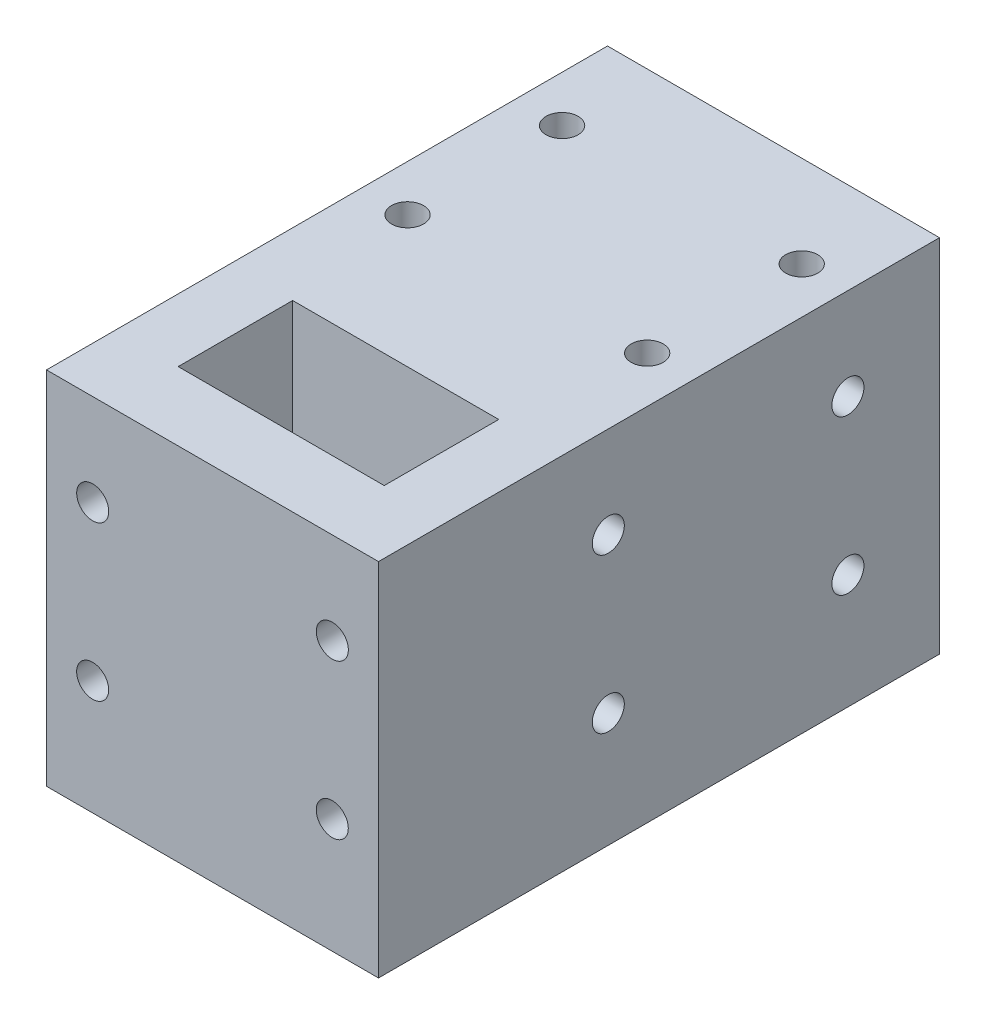
from build123d import *

# Parameters (mm, degrees)
SKETCH1_W           = 29
SKETCH1_H           = 49
BOSS_EXTRUDE1_DEPTH = 31.5
SKETCH2_W           = 18
SKETCH2_H           = 10
CUT_EXTRUDE1_DEPTH  = 32.5
SKETCH3_R           = 1.4
CUT_EXTRUDE2_DEPTH  = 3.4
SKETCH4_R           = 1.4
CUT_EXTRUDE3_DEPTH  = 3.4
SKETCH5_R           = 1.4
CUT_EXTRUDE4_DEPTH  = 3.4
CUT_EXTRUDE5_DEPTH  = 12


with BuildPart() as part:
    # Sketch1 → Boss-Extrude1 (new body)
    with BuildSketch(Plane(origin=(0, 0, 0), x_dir=(1, 0, 0), z_dir=(0, 1, 0))):
        with Locations((-2.710031348, 9.123824451)):
            Rectangle(SKETCH1_W, SKETCH1_H)
    extrude(amount=BOSS_EXTRUDE1_DEPTH)

    # Sketch2 → Cut-Extrude1 (cut, through all)
    with BuildSketch(Plane(origin=(0, 31.5, 0), x_dir=(1, 0, 0), z_dir=(0, 1, 0))):
        with Locations((-2.710031348, -4.376175549)):
            Rectangle(SKETCH2_W, SKETCH2_H)
    extrude(amount=-CUT_EXTRUDE1_DEPTH, mode=Mode.SUBTRACT)

    # Sketch3 → Cut-Extrude2 (cut)
    with BuildSketch(Plane(origin=(0, 31.5, 0), x_dir=(1, 0, 0), z_dir=(0, 1, 0))):
        with Locations((-13.175031348, 25.623824451)):
            Circle(SKETCH3_R)
        with Locations((-13.175031348, 12.123824451)):
            Circle(SKETCH3_R)
        with Locations((7.754968652, 25.623824451)):
            Circle(SKETCH3_R)
        with Locations((7.754968652, 12.123824451)):
            Circle(SKETCH3_R)
    extrude(amount=-CUT_EXTRUDE2_DEPTH, mode=Mode.SUBTRACT)

    # Sketch4 → Cut-Extrude3 (cut)
    with BuildSketch(Plane.ZY.offset(17.210031348)):
        with Locations((-25.623824451, 23.5)):
            Circle(SKETCH4_R)
        with Locations((-4.693824451, 23.5)):
            Circle(SKETCH4_R)
        with Locations((-25.623824451, 10)):
            Circle(SKETCH4_R)
        with Locations((-4.693824451, 10)):
            Circle(SKETCH4_R)
    cut_extrude3 = extrude(amount=-CUT_EXTRUDE3_DEPTH, mode=Mode.SUBTRACT)

    # Mirror1: Cut-Extrude3 across plane
    add(cut_extrude3.mirror(Plane.ZY.offset(2.710031348)), mode=Mode.SUBTRACT)

    # Sketch5 → Cut-Extrude4 (cut)
    with BuildSketch(Plane.XY.offset(15.376175549)):
        with Locations((-13.175031348, 23.5)):
            Circle(SKETCH5_R)
        with Locations((7.754968652, 23.5)):
            Circle(SKETCH5_R)
        with Locations((-13.180031348, 10)):
            Circle(SKETCH5_R)
        with Locations((7.749968652, 10)):
            Circle(SKETCH5_R)
    cut_extrude4 = extrude(amount=-CUT_EXTRUDE4_DEPTH, mode=Mode.SUBTRACT)

    # Mirror2: Cut-Extrude4 across plane
    add(cut_extrude4.mirror(Plane.XY.offset(-9.123824451)), mode=Mode.SUBTRACT)

    # Sketch7 → Cut-Extrude5 (cut)
    with BuildSketch(Plane.XZ):
        Polygon((3.929496748, -17.123824451), (0.6097327, -11.373824451), (-6.029795396, -11.373824451), (-9.349559444, -17.123824451), (-6.029795396, -22.873824451), (0.6097327, -22.873824451), align=None)
    extrude(amount=-CUT_EXTRUDE5_DEPTH, mode=Mode.SUBTRACT)


solid = part.part
